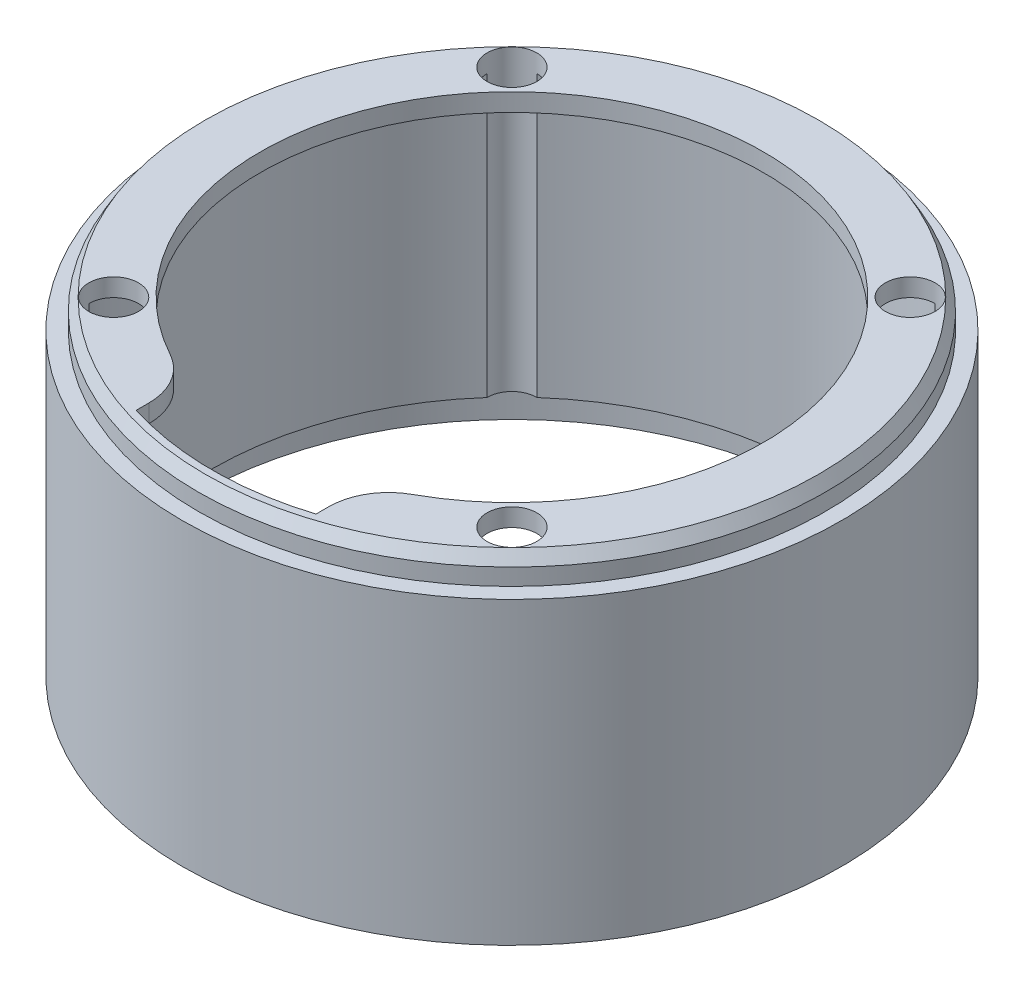
from build123d import *

# Parameters (mm, degrees)
SKETCH1_R           = 55
BOSS_EXTRUDE1_DEPTH = 54.8
SHELL1_T            = -5
SKETCH2_R           = 35
CUT_EXTRUDE1_DEPTH  = 6
SKETCH3_R           = 42
CUT_EXTRUDE2_DEPTH  = 55.8
SKETCH4_R           = 4.15
CUT_EXTRUDE3_DEPTH  = 55.8
SKETCH6_R           = 50
CUT_EXTRUDE4_DEPTH  = 2
CUT_EXTRUDE5_DEPTH  = 4
FILLET1_R           = 10
SKETCH8_OUTSIDE_W   = 144.986
SKETCH8_OUTSIDE_H   = 144.986
SKETCH8_OUTSIDE_R   = 52.35
CUT_EXTRUDE6_DEPTH  = 4.8
CHAMFER1_SIZE       = 2
CHAMFER1_SIZE2      = 1.154700538
SKETCH9_R           = 52.5
CUT_EXTRUDE7_DEPTH  = 5


with BuildPart() as part:
    # Sketch1 → Boss-Extrude1 (new body)
    with BuildSketch(Plane(origin=(0, 0, 0), x_dir=(1, 0, 0), z_dir=(0, 1, 0))):
        with Locations(Location((0, 0, 0), (0, 0, 270))):  # turned: the seam where the file's is
            Circle(SKETCH1_R)
    extrude(amount=BOSS_EXTRUDE1_DEPTH)

    # Shell1
    shell1_openings = [part.faces().sort_by_distance(p)[0] for p in [
        (0, 0, 0),
    ]]
    offset(amount=SHELL1_T, openings=shell1_openings, kind=Kind.INTERSECTION)

    # Sketch2 → Cut-Extrude1 (cut, through all)
    with BuildSketch(Plane.XZ.offset(-49.8)):
        with Locations(Location((0, 0, 0), (0, 0, 270))):  # turned: the seam where the file's is
            Circle(SKETCH2_R)
    extrude(amount=-CUT_EXTRUDE1_DEPTH, mode=Mode.SUBTRACT)

    # Sketch3 → Cut-Extrude2 (cut, through all)
    with BuildSketch(Plane(origin=(0, 54.8, 0), x_dir=(1, 0, 0), z_dir=(0, 1, 0))):
        with Locations(Location((0, 0, 0), (0, 0, 270))):  # turned: the seam where the file's is
            Circle(SKETCH3_R)
    extrude(amount=-CUT_EXTRUDE2_DEPTH, mode=Mode.SUBTRACT)

    # Sketch4 → Cut-Extrude3 (cut, through all)
    with BuildSketch(Plane(origin=(0, 54.8, 0), x_dir=(1, 0, 0), z_dir=(0, 1, 0))):
        with Locations(Location((-33.234018716, -33.234018716, 0), (0, 0, 270))):  # turned: the seam where the file's is
            Circle(SKETCH4_R)
        with Locations(Location((-33.234018716, 33.234018716, 0), (0, 0, 270))):  # turned: the seam where the file's is
            Circle(SKETCH4_R)
        with Locations(Location((33.234018716, 33.234018716, 0), (0, 0, 270))):  # turned: the seam where the file's is
            Circle(SKETCH4_R)
        with Locations(Location((33.234018716, -33.234018716, 0), (0, 0, 270))):  # turned: the seam where the file's is
            Circle(SKETCH4_R)
    extrude(amount=-CUT_EXTRUDE3_DEPTH, mode=Mode.SUBTRACT)

    # Sketch6 → Cut-Extrude4 (cut)
    with BuildSketch(Plane.XZ.offset(-49.8)):
        Circle(SKETCH6_R)
    extrude(amount=-CUT_EXTRUDE4_DEPTH, mode=Mode.SUBTRACT)

    # Sketch7 → Cut-Extrude5 (cut, through all)
    with BuildSketch(Plane.XZ.offset(-51.8)):
        with BuildLine():
            Line((15, 33.234018716), (15, 47.696960071))
            ThreePointArc((15, 47.696960071), (0, 50), (-15, 47.696960071))
            Line((-15, 47.696960071), (-15, 33.234018716))
            Line((-15, 33.234018716), (15, 33.234018716))
        make_face()
    extrude(amount=-CUT_EXTRUDE5_DEPTH, mode=Mode.SUBTRACT)

    # Fillet1
    fillet1_edges = [part.edges().sort_by_distance(p)[0] for p in [
        (-15, 53.3, 39.230090492),
        (15, 53.3, 39.230090492),
    ]]
    fillet(fillet1_edges, radius=FILLET1_R)

    # Sketch8 outside → Cut-Extrude6 (cut)
    with BuildSketch(Plane(origin=(0, 54.8, 0), x_dir=(1, 0, 0), z_dir=(0, 1, 0))):
        Rectangle(SKETCH8_OUTSIDE_W, SKETCH8_OUTSIDE_H)
        with Locations(Location((0, 0, 0), (0, 0, 270))):  # turned: the seam where the file's is
            Circle(SKETCH8_OUTSIDE_R, mode=Mode.SUBTRACT)
    extrude(amount=-CUT_EXTRUDE6_DEPTH, mode=Mode.SUBTRACT)

    # Chamfer1
    chamfer1_edges = [part.edges().sort_by_distance(p)[0] for p in [
        (0, 54.8, -52.35),
    ]]
    chamfer1_side = [part.faces().sort_by_distance(p)[0] for p in [
        (0, 52.4, -52.35),
    ]]
    chamfer(chamfer1_edges, length=CHAMFER1_SIZE, length2=CHAMFER1_SIZE2, reference=chamfer1_side[0])

    # Sketch9 → Cut-Extrude7 (cut)
    with BuildSketch(Plane.XZ):
        with Locations(Location((0, 0, 0), (0, 0, 270))):  # turned: the seam where the file's is
            Circle(SKETCH9_R)
    extrude(amount=-CUT_EXTRUDE7_DEPTH, mode=Mode.SUBTRACT)


solid = part.part
